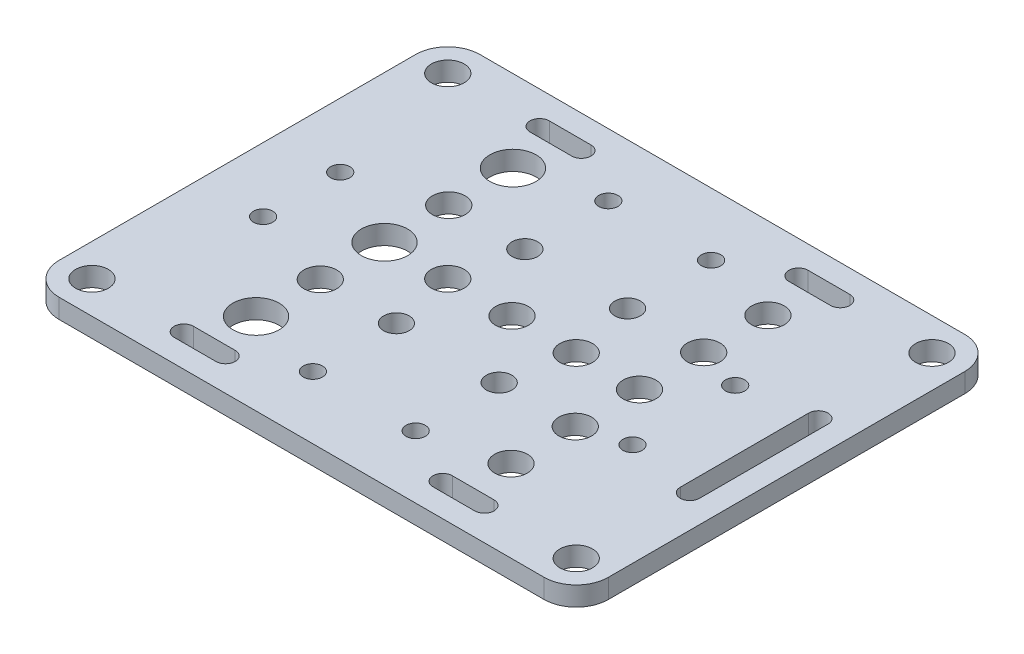
from build123d import *

# Parameters (mm, degrees)
SKETCH1_R           = 2.55
SKETCH1_R_2         = 1.5
SKETCH1_R_3         = 2
SKETCH1_R_4         = 3.6
BOSS_EXTRUDE1_DEPTH = 3


with BuildPart() as part:
    # Sketch1 → Boss-Extrude1 (new body)
    with BuildSketch(Plane(origin=(0, 0, 0), x_dir=(1, 0, 0), z_dir=(0, 1, 0))):
        with BuildLine():
            Line((27.75, -32.75), (-27.75, -32.75))
            Line((-27.75, -32.75), (-37.75, -32.75))
            ThreePointArc((-37.75, -32.75), (-41.285533906, -31.285533906), (-42.75, -27.75))
            Line((-42.75, -27.75), (-42.75, 27.75))
            ThreePointArc((-42.75, 27.75), (-41.285533906, 31.285533906), (-37.75, 32.75))
            Line((-37.75, 32.75), (-27.75, 32.75))
            Line((-27.75, 32.75), (27.75, 32.75))
            Line((27.75, 32.75), (37.75, 32.75))
            ThreePointArc((37.75, 32.75), (41.285533906, 31.285533906), (42.75, 27.75))
            Line((42.75, 27.75), (42.75, -27.75))
            ThreePointArc((42.75, -27.75), (41.285533906, -31.285533906), (37.75, -32.75))
            Line((37.75, -32.75), (27.75, -32.75))
        make_face()
        with Locations((37.7, 27.7)):
            Circle(SKETCH1_R, mode=Mode.SUBTRACT)
        with Locations((37.7, -27.7)):
            Circle(SKETCH1_R, mode=Mode.SUBTRACT)
        with Locations((-37.7, -27.7)):
            Circle(SKETCH1_R, mode=Mode.SUBTRACT)
        with Locations((-37.7, 27.7)):
            Circle(SKETCH1_R, mode=Mode.SUBTRACT)
        with Locations((-8, 23)):
            Circle(SKETCH1_R_2, mode=Mode.SUBTRACT)
        with Locations((-8, 10)):
            Circle(SKETCH1_R_3, mode=Mode.SUBTRACT)
        Circle(SKETCH1_R, mode=Mode.SUBTRACT)
        with Locations((10, 0)):
            Circle(SKETCH1_R, mode=Mode.SUBTRACT)
        with Locations((-10, 0)):
            Circle(SKETCH1_R, mode=Mode.SUBTRACT)
        with Locations((-19.85, 20)):
            Circle(SKETCH1_R_4, mode=Mode.SUBTRACT)
        with Locations((-19.85, 0)):
            Circle(SKETCH1_R_4, mode=Mode.SUBTRACT)
        with Locations((-19.85, -20)):
            Circle(SKETCH1_R_4, mode=Mode.SUBTRACT)
        with Locations((8, 23)):
            Circle(SKETCH1_R_2, mode=Mode.SUBTRACT)
        with Locations((-8, -10)):
            Circle(SKETCH1_R_3, mode=Mode.SUBTRACT)
        with Locations((8, -10)):
            Circle(SKETCH1_R_3, mode=Mode.SUBTRACT)
        with Locations((8, 10)):
            Circle(SKETCH1_R_3, mode=Mode.SUBTRACT)
        with Locations((-19.85, 10)):
            Circle(SKETCH1_R, mode=Mode.SUBTRACT)
        with Locations((-8, -23)):
            Circle(SKETCH1_R_2, mode=Mode.SUBTRACT)
        with Locations((8, -23)):
            Circle(SKETCH1_R_2, mode=Mode.SUBTRACT)
        with Locations((-32.75, 6)):
            Circle(SKETCH1_R_2, mode=Mode.SUBTRACT)
        with Locations((19.85, 20)):
            Circle(SKETCH1_R, mode=Mode.SUBTRACT)
        with Locations((19.85, 0)):
            Circle(SKETCH1_R, mode=Mode.SUBTRACT)
        with Locations((19.85, -20)):
            Circle(SKETCH1_R, mode=Mode.SUBTRACT)
        with Locations((-32.75, -6)):
            Circle(SKETCH1_R_2, mode=Mode.SUBTRACT)
        with Locations((26.75, 8)):
            Circle(SKETCH1_R_2, mode=Mode.SUBTRACT)
        with Locations((26.766687539, -7.999991298)):
            Circle(SKETCH1_R_2, mode=Mode.SUBTRACT)
        with Locations((19.85, 10)):
            Circle(SKETCH1_R, mode=Mode.SUBTRACT)
        with Locations((19.85, -10)):
            Circle(SKETCH1_R, mode=Mode.SUBTRACT)
        with Locations((-19.85, -10)):
            Circle(SKETCH1_R, mode=Mode.SUBTRACT)
        with BuildLine():
            Line((39.2, 10), (39.2, -10))
            ThreePointArc((39.2, -10), (37.7, -11.5), (36.2, -10))
            Line((36.2, -10), (36.2, 10))
            ThreePointArc((36.2, 10), (37.7, 11.5), (39.2, 10))
        make_face(mode=Mode.SUBTRACT)
        with BuildLine():
            Line((-16.9, 26.2), (-23.4, 26.2))
            ThreePointArc((-23.4, 26.2), (-24.9, 27.7), (-23.4, 29.2))
            Line((-23.4, 29.2), (-16.9, 29.2))
            ThreePointArc((-16.9, 29.2), (-15.4, 27.7), (-16.9, 26.2))
        make_face(mode=Mode.SUBTRACT)
        with BuildLine():
            Line((16.9, 26.2), (23.4, 26.2))
            ThreePointArc((23.4, 26.2), (24.9, 27.7), (23.4, 29.2))
            Line((23.4, 29.2), (16.9, 29.2))
            ThreePointArc((16.9, 29.2), (15.4, 27.7), (16.9, 26.2))
        make_face(mode=Mode.SUBTRACT)
        with BuildLine():
            Line((-16.9, -26.2), (-23.4, -26.2))
            ThreePointArc((-23.4, -26.2), (-24.9, -27.7), (-23.4, -29.2))
            Line((-23.4, -29.2), (-16.9, -29.2))
            ThreePointArc((-16.9, -29.2), (-15.4, -27.7), (-16.9, -26.2))
        make_face(mode=Mode.SUBTRACT)
        with BuildLine():
            Line((16.9, -26.2), (23.4, -26.2))
            ThreePointArc((23.4, -26.2), (24.9, -27.7), (23.4, -29.2))
            Line((23.4, -29.2), (16.9, -29.2))
            ThreePointArc((16.9, -29.2), (15.4, -27.7), (16.9, -26.2))
        make_face(mode=Mode.SUBTRACT)
    extrude(amount=BOSS_EXTRUDE1_DEPTH)


solid = part.part
